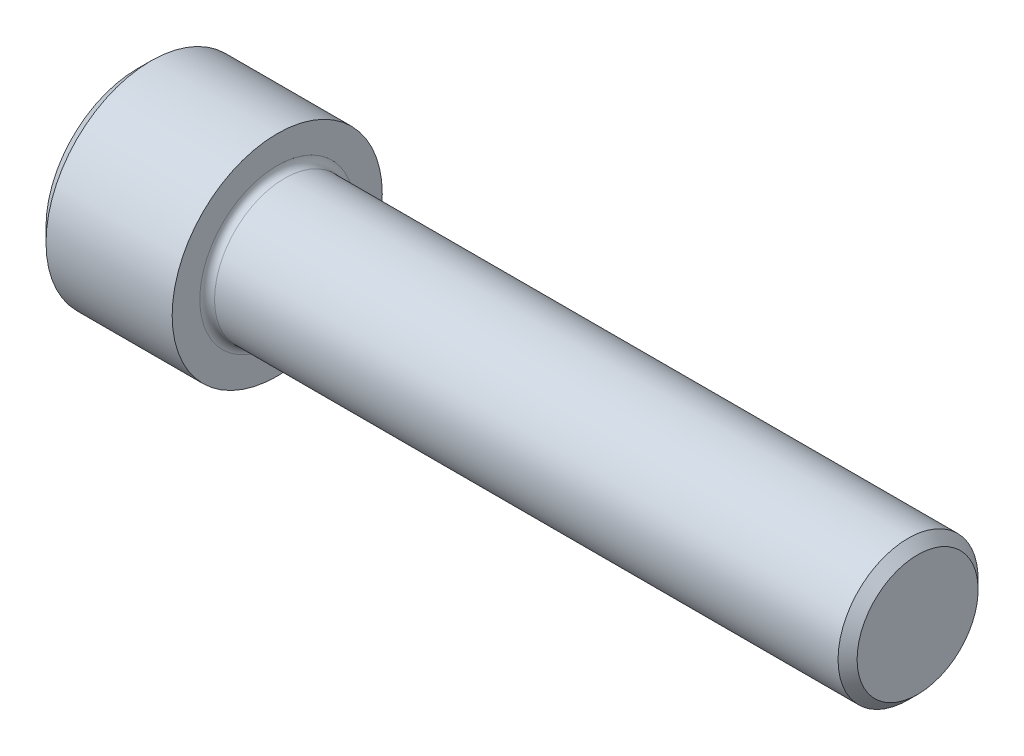
from build123d import *

# Parameters (mm, degrees)
FILLET1_R   = 0.5842
HEX_2_DEPTH = 5.4102


with BuildPart() as part:
    # BodySke → Base-Revolve (revolve)
    with BuildSketch(Plane.XY):
        Polygon((0, 0), (0, 7.23011), (1.1049, 8.33501), (11.1125, 8.33501), (11.1125, 5.55625), (61.15685, 5.55625), (61.9125, 4.8006), (61.9125, 0), align=None)
    revolve(axis=Axis((-31.75, 0, 0), (1, 0, 0)))

    # Fillet1
    fillet1_edges = [part.edges().sort_by_distance(p)[0] for p in [
        (11.1125, -5.55625, 0),
    ]]
    fillet(fillet1_edges, radius=FILLET1_R)

    # Sketch2 → Hex-PreBroach (revolve, cut)
    with BuildSketch(Plane.XY):
        Polygon((0, 4.7625), (5.4102, 4.7625), (8.159830657, 0), (0, 0), align=None)
    revolve(axis=Axis((0, 0, 0), (1, 0, 0)), mode=Mode.SUBTRACT)

    # Sketch3 → Hex 2 (cut)
    with BuildSketch(Plane(origin=(0, 0, 0), x_dir=(0, 0.5, 0.866025404), z_dir=(-1, 0, 0))):
        Polygon((2.749630657, 4.7625), (-2.749630657, 4.7625), (-5.499261314, 0), (-2.749630657, -4.7625), (2.749630657, -4.7625), (5.499261314, 0), align=None)
    extrude(amount=-HEX_2_DEPTH, mode=Mode.SUBTRACT)


solid = part.part
